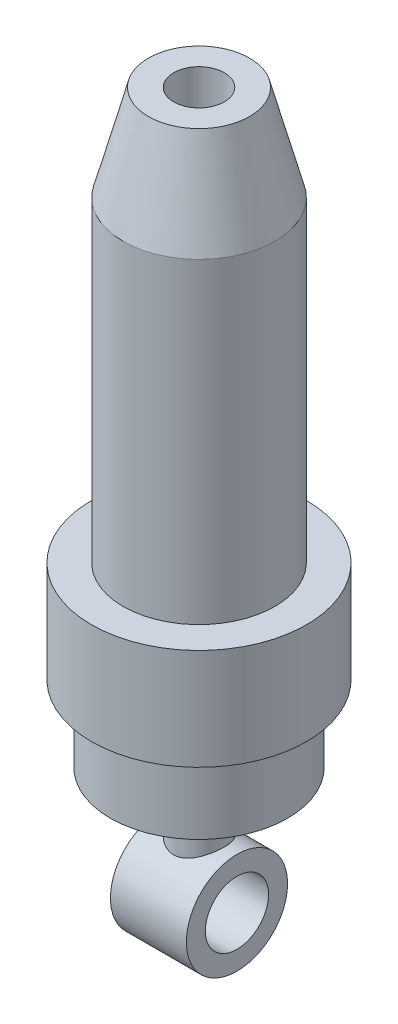
from build123d import *

# Parameters (mm, degrees)
EXTRUDE_1_DEPTH          = 3
EXTRUDE_1_DEPTH_BACK     = 3
SKETCH_1_R               = 4.5
SKETCH_1_R_2             = 1.5000000000000007
EXTRUDE_1_2_DEPTH        = 3
EXTRUDE_1_2_DEPTH_BACK   = 3
SKETCH_1_R_3             = 4.000000000000001
SKETCH_1_R_4             = 2.500000000000001
EXTRUDE_2_REACH          = 71.212
EXTRUDE_2_END_RADIUS     = 4.5
SKETCH_2_R               = 3
SKETCH_3_R               = 3
CUT_EXTRUDE_1_DEPTH      = 10
SKETCH_4_R               = 2
EXTRUDE_3_DEPTH          = 20
CUT_EXTRUDE_2_DEPTH      = 20
CUT_EXTRUDE_2_DEPTH_BACK = 20
CUT_EXTRUDE_START        = -30
SKETCH_7_R               = 2
CUT_EXTRUDE_3_DEPTH      = 30


with BuildPart() as part:
    # 草图1 → 凸台-拉伸1 (new, two sides: drawn at the far end of the back side and taken through both)
    with BuildSketch(Plane(origin=(0, 0, 0), x_dir=(0, 0, -1), z_dir=(1, 0, 0)).offset(-EXTRUDE_1_DEPTH_BACK)):
        with Locations((0, 20)):
            Circle(SKETCH_1_R)
        with Locations((0, 20)):
            Circle(SKETCH_1_R_2, mode=Mode.SUBTRACT)
    extrude(amount=EXTRUDE_1_DEPTH + EXTRUDE_1_DEPTH_BACK)

    # 凸台-拉伸2: up to this cylinder (the profile starts outside it)
    extrude_2_end = Plane(origin=(0, 20, 0), z_dir=(1, 0, 0)) * Cylinder(EXTRUDE_2_END_RADIUS, 152.424, mode=Mode.PRIVATE)
    # 草图2 → 凸台-拉伸2 (add, up to the surface)
    with BuildSketch(Plane(origin=(0, 0, 0), x_dir=(1, 0, 0), z_dir=(0, 1, 0)), mode=Mode.PRIVATE) as extrude_2_sk1:
        Circle(SKETCH_2_R)
    extrude_2_tool1 = extrude(extrude_2_sk1.sketch, amount=EXTRUDE_2_REACH, mode=Mode.PRIVATE) - extrude_2_end
    add(extrude_2_tool1.solids().sort_by_distance((0, 0, 0))[0])

    # 草图3 → 切除-拉伸1 (cut)
    with BuildSketch(Plane.XZ):
        Circle(SKETCH_3_R)
    extrude(amount=-CUT_EXTRUDE_1_DEPTH, mode=Mode.SUBTRACT)

    # 草图4 → 凸台-拉伸3 (add)
    with BuildSketch(Plane.XZ.offset(-10)):
        Circle(SKETCH_4_R)
    extrude(amount=EXTRUDE_3_DEPTH)



with BuildPart() as body_2:
    # 草图1 → Extrude 1 2 (new, two sides: drawn at the far end of the back side and taken through both)
    with BuildSketch(Plane(origin=(0, 0, 0), x_dir=(0, 0, -1), z_dir=(1, 0, 0)).offset(-EXTRUDE_1_2_DEPTH_BACK)):
        with Locations((1.041e-14, -65)):
            Circle(SKETCH_1_R_3)
        with Locations((1.041e-14, -65)):
            Circle(SKETCH_1_R_4, mode=Mode.SUBTRACT)
    extrude(amount=EXTRUDE_1_2_DEPTH + EXTRUDE_1_2_DEPTH_BACK)


with BuildPart() as part_1:
    add(part.part)

    add(body_2.part)  # 旋转2 merges body 2
    # 草图5 → 旋转2 (revolve)
    with BuildSketch(Plane(origin=(0, 0, 0), x_dir=(0, 0, -1), z_dir=(1, 0, 0))):
        Polygon((0, -10), (4, -10), (6, -17.535898384862247), (6.0000000000000036, -42.53589838486224), (8.500000000000004, -42.53589838486224), (8.500000000000005, -50.53589838486224), (7.000000000000005, -50.53589838486224), (7.000000000000006, -56.53589838486224), (2.0000000000000053, -56.53589838486225), (2.0000000000000067, -61.53589838486224), (1.041e-14, -61), align=None)
    revolve(axis=Axis((0, -10, 0), (0, -1, -2e-16)))

    # 草图6 → 切除-拉伸2 (cut, two sides: drawn at the far end of the back side and taken through both)
    with BuildSketch(Plane(origin=(0, 0, 0), x_dir=(0, 0, -1), z_dir=(1, 0, 0)).offset(-CUT_EXTRUDE_2_DEPTH_BACK)):
        Polygon((4, -9.999999999999998), (-4, -10.000000000000002), (-9.63230113764052, 30.28895780179854), (12.266588859338443, 30.28895780179854), align=None)
    extrude(amount=CUT_EXTRUDE_2_DEPTH + CUT_EXTRUDE_2_DEPTH_BACK, mode=Mode.SUBTRACT)

    # 草图7 → 切除-拉伸3 (cut)
    with BuildSketch(Plane(origin=(0, -10, -2.04e-15), x_dir=(1, 0, 0), z_dir=(0, 1, 2e-16)).offset(CUT_EXTRUDE_START)):
        Circle(SKETCH_7_R)
    extrude(amount=CUT_EXTRUDE_3_DEPTH, mode=Mode.SUBTRACT)


solid = part_1.part
